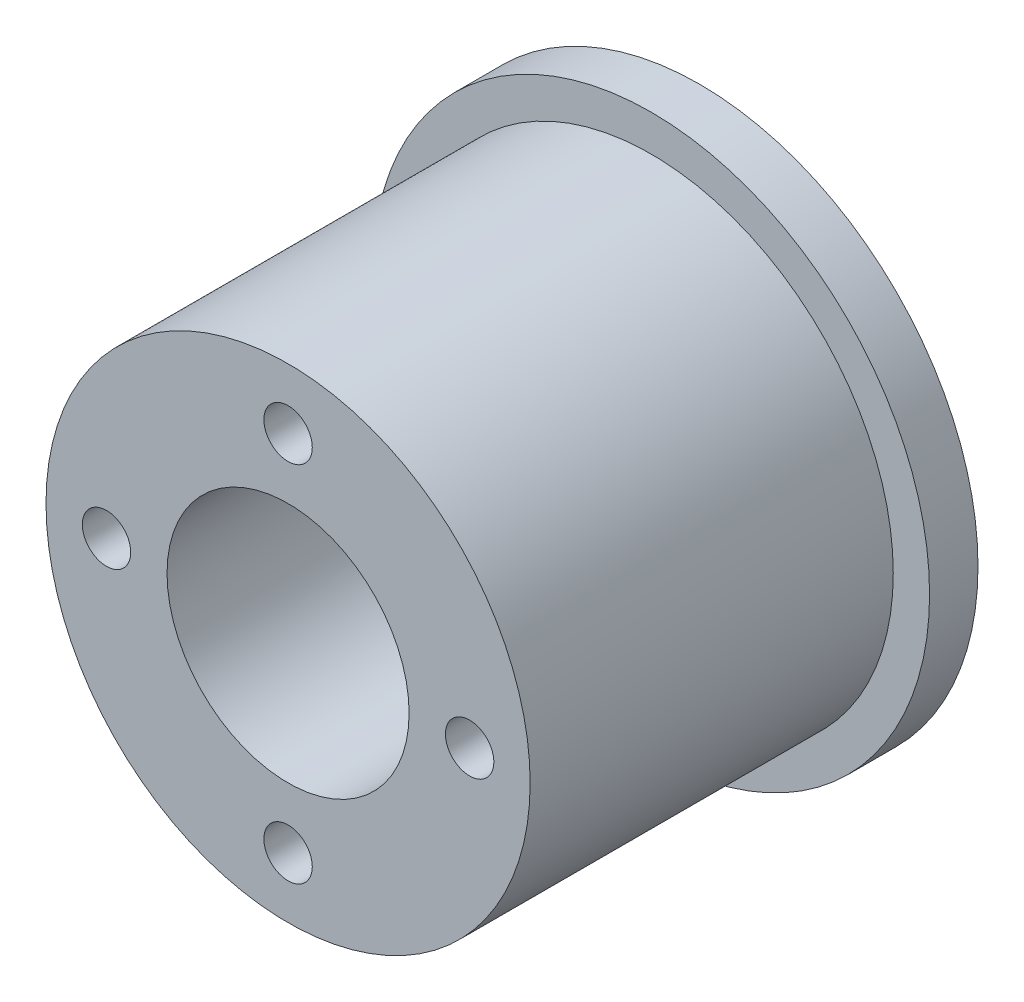
from build123d import *

# Parameters (mm, degrees)
SKETCH1_R           = 23
SKETCH1_R_2         = 10
BOSS_EXTRUDE1_DEPTH = 4
SKETCH2_R           = 20
SKETCH2_R_2         = 10
SKETCH2_R_3         = 2
BOSS_EXTRUDE2_DEPTH = 30


with BuildPart() as part:
    # Sketch1 → Boss-Extrude1 (new body)
    with BuildSketch(Plane.XY):
        Circle(SKETCH1_R)
        Circle(SKETCH1_R_2, mode=Mode.SUBTRACT)
    extrude(amount=BOSS_EXTRUDE1_DEPTH)

    # Sketch2 → Boss-Extrude2 (add)
    with BuildSketch(Plane.XY.offset(4)):
        Circle(SKETCH2_R)
        Circle(SKETCH2_R_2, mode=Mode.SUBTRACT)
        with Locations((0, 15)):
            Circle(SKETCH2_R_3, mode=Mode.SUBTRACT)
        with Locations((15, 0)):
            Circle(SKETCH2_R_3, mode=Mode.SUBTRACT)
        with Locations((0, -15)):
            Circle(SKETCH2_R_3, mode=Mode.SUBTRACT)
        with Locations((-15, 0)):
            Circle(SKETCH2_R_3, mode=Mode.SUBTRACT)
    extrude(amount=BOSS_EXTRUDE2_DEPTH)


solid = part.part
